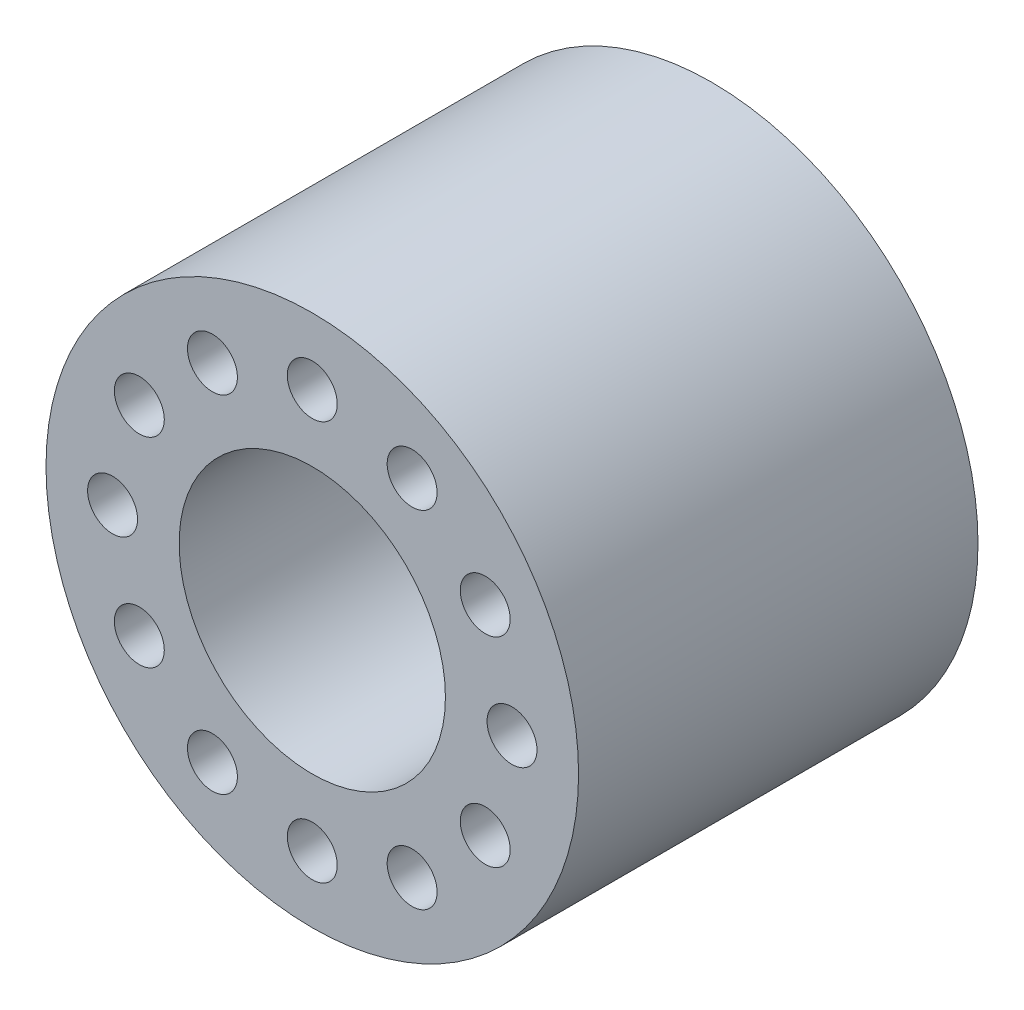
from build123d import *

# Parameters (mm, degrees)
SKETCH_1_R      = 8
SKETCH_1_R_2    = 0.75
SKETCH_1_R_3    = 4
EXTRUDE_1_DEPTH = 12


with BuildPart() as part:
    # 草图1 → 凸台-拉伸1 (new body)
    with BuildSketch(Plane.XY):
        Circle(SKETCH_1_R)
        with Locations((6, 0)):
            Circle(SKETCH_1_R_2, mode=Mode.SUBTRACT)
        with Locations((5.196152423, -3)):
            Circle(SKETCH_1_R_2, mode=Mode.SUBTRACT)
        with Locations((3, -5.196152423)):
            Circle(SKETCH_1_R_2, mode=Mode.SUBTRACT)
        with Locations((0, -6)):
            Circle(SKETCH_1_R_2, mode=Mode.SUBTRACT)
        with Locations((-3, -5.196152423)):
            Circle(SKETCH_1_R_2, mode=Mode.SUBTRACT)
        with Locations((-5.196152423, -3)):
            Circle(SKETCH_1_R_2, mode=Mode.SUBTRACT)
        with Locations((-6, 0)):
            Circle(SKETCH_1_R_2, mode=Mode.SUBTRACT)
        with Locations((-5.196152423, 3)):
            Circle(SKETCH_1_R_2, mode=Mode.SUBTRACT)
        with Locations((-3, 5.196152423)):
            Circle(SKETCH_1_R_2, mode=Mode.SUBTRACT)
        with Locations((0, 6)):
            Circle(SKETCH_1_R_2, mode=Mode.SUBTRACT)
        with Locations((3, 5.196152423)):
            Circle(SKETCH_1_R_2, mode=Mode.SUBTRACT)
        with Locations((5.196152423, 3)):
            Circle(SKETCH_1_R_2, mode=Mode.SUBTRACT)
        Circle(SKETCH_1_R_3, mode=Mode.SUBTRACT)
    extrude(amount=EXTRUDE_1_DEPTH)


solid = part.part
